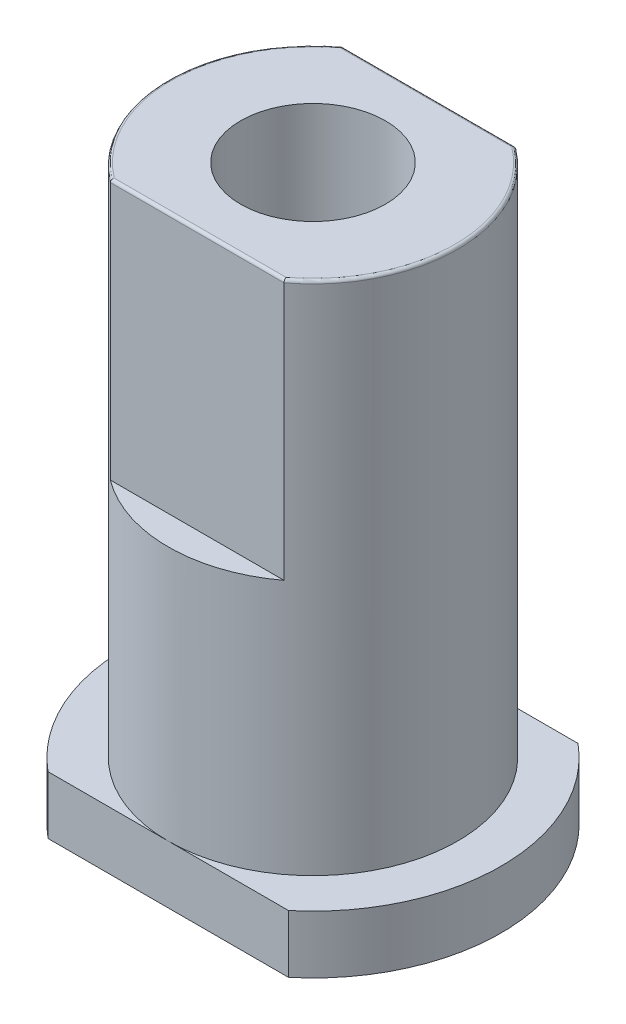
from build123d import *

# Parameters (mm, degrees)
SKETCH_1_R          = 5
SKETCH_1_R_2        = 2.5
EXTRUDE_1_DEPTH     = 17.8
CUT_EXTRUDE_1_DEPTH = 9
SKETCH_4_R          = 2.5
EXTRUDE_2_DEPTH     = 2
FILLET_1_R          = 0.1


with BuildPart() as part:
    # 草图1 → 凸台-拉伸1 (new body)
    with BuildSketch(Plane(origin=(0, 0, 0), x_dir=(1, 0, 0), z_dir=(0, 1, 0))):
        Circle(SKETCH_1_R)
        Circle(SKETCH_1_R_2, mode=Mode.SUBTRACT)
    extrude(amount=EXTRUDE_1_DEPTH)

    # 草图3 → 切除-拉伸1 (cut)
    with BuildSketch(Plane(origin=(0, 17.8, 0), x_dir=(1, 0, 0), z_dir=(0, 1, 0))):
        with BuildLine():
            Line((-3, -4), (3, -4))
            ThreePointArc((3, -4), (0, -5), (-3, -4))
        make_face()
        with BuildLine():
            Line((-3, 4), (3, 4))
            ThreePointArc((3, 4), (0, 5), (-3, 4))
        make_face()
    extrude(amount=-CUT_EXTRUDE_1_DEPTH, mode=Mode.SUBTRACT)

    # 草图4 → 凸台-拉伸2 (add)
    with BuildSketch(Plane.XZ):
        with BuildLine():
            Line((-4.153311931, 5), (4.153311931, 5))
            ThreePointArc((4.153311931, 5), (6.5, 0), (4.153311931, -5))
            Line((4.153311931, -5), (-4.153311931, -5))
            ThreePointArc((-4.153311931, -5), (-6.5, 0), (-4.153311931, 5))
        make_face()
        Circle(SKETCH_4_R, mode=Mode.SUBTRACT)
    extrude(amount=EXTRUDE_2_DEPTH)

    # 圆角1
    fillet_1_edges = [part.edges().sort_by_distance(p)[0] for p in [
        (0, 17.8, 4),
        (-5, 17.8, 0),
        (0, 17.8, -4),
        (4.472135955, 17.8, 2.236067977),
    ]]
    fillet(fillet_1_edges, radius=FILLET_1_R)


solid = part.part
